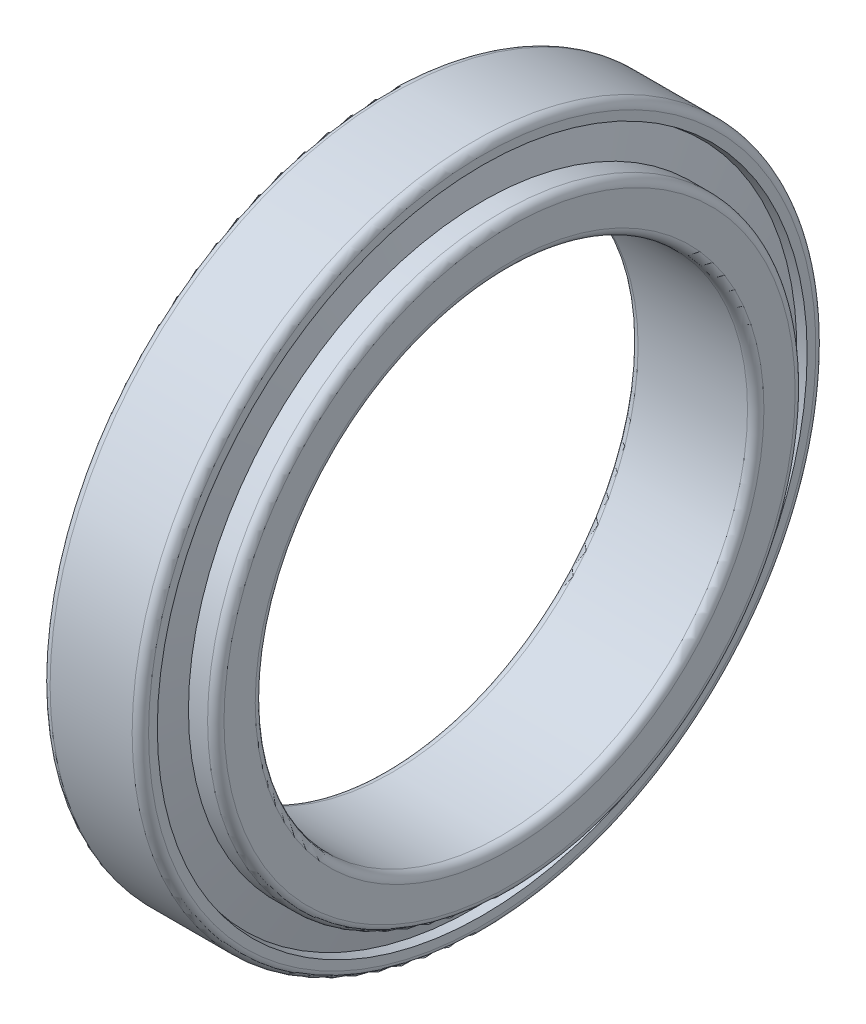
from build123d import *


with BuildPart() as part:
    # Эскиз1 → Повернуть1 (revolve)
    with BuildSketch(Plane.XY):
        with BuildLine():
            Line((1.689053993, 55.993760926), (0, 55.641))
            Line((0, 55.641), (0, 61))
            ThreePointArc((0, 61), (0.439339828, 62.060660172), (1.5, 62.5))
            Line((1.5, 62.5), (16.5, 62.5))
            ThreePointArc((16.5, 62.5), (17.560660172, 62.060660172), (18, 61))
            Line((18, 61), (18, 59.400321308))
            Line((18, 59.400321308), (16.434107985, 59.073282907))
            Line((16.434107985, 59.073282907), (18, 52.208717093))
            Line((18, 52.208717093), (18, 53.708717093))
            Line((18, 53.708717093), (21.5, 53.708717093))
            ThreePointArc((21.5, 53.708717093), (22.560660172, 53.269377265), (23, 52.208717093))
            Line((23, 52.208717093), (23, 46.5))
            ThreePointArc((23, 46.5), (22.560660172, 45.439339828), (21.5, 45))
            Line((21.5, 45), (1.5, 45))
            ThreePointArc((1.5, 45), (0.439339828, 45.439339828), (0, 46.5))
            Line((0, 46.5), (0, 48.58927697))
            Line((0, 48.58927697), (3.378107986, 48.58927697))
            Line((3.378107986, 48.58927697), (1.689053993, 55.993760926))
        make_face()
    revolve(axis=Axis((-882.527700014, 0, 0), (1, 0, 0)))


solid = part.part
